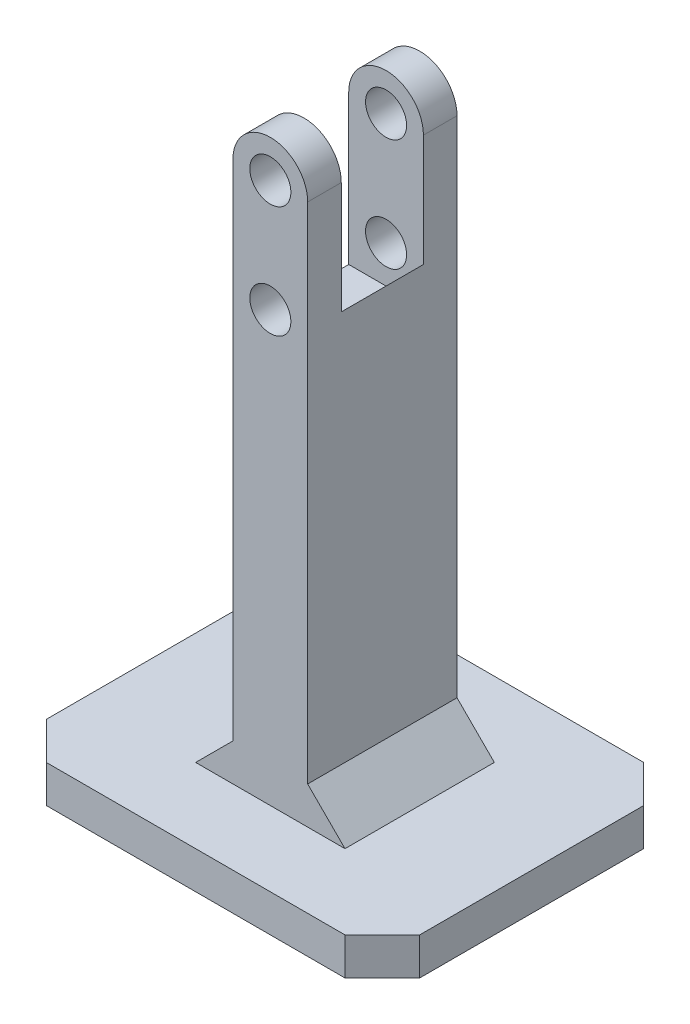
from build123d import *

# Parameters (mm, degrees)
BOSS_EXTRUDE1_DEPTH  = 10
M5_CLEARANCE_HOLE1_D = 5.5
CUT_EXTRUDE1_DEPTH   = 5.5
BOSS_EXTRUDE2_DEPTH  = 20
CHAMFER1_SIZE        = 5


with BuildPart() as part:
    # Sketch1 → Boss-Extrude1 (new, symmetric)
    with BuildSketch(Plane.XY):
        with BuildLine():
            Line((-5, -65), (-25, -65))
            Line((-25, -65), (-25, -70))
            Line((-25, -70), (25, -70))
            Line((25, -70), (25, -65))
            Line((25, -65), (5, -65))
            Line((5, -65), (5, 7.5))
            ThreePointArc((5, 7.5), (0, 12.5), (-5, 7.5))
            Line((-5, 7.5), (-5, -65))
        make_face()
    extrude(amount=BOSS_EXTRUDE1_DEPTH, both=True)

    # M5 Clearance Hole1 (through all)
    with Locations(Plane.XY.offset(10)):
        with Locations((0, 7.5), (0, -7.5)):
            Hole(M5_CLEARANCE_HOLE1_D / 2)

    # Sketch1_3 → Cut-Extrude1 (cut, symmetric)
    with BuildSketch(Plane.XY):
        with BuildLine():
            ThreePointArc((0, -12.5), (3.535533906, -11.035533906), (5, -7.5))
            Line((5, -7.5), (5, 7.5))
            ThreePointArc((5, 7.5), (0, 12.5), (-5, 7.5))
            Line((-5, 7.5), (-5, -12.5))
            Line((-5, -12.5), (0, -12.5))
        make_face()
    extrude(amount=CUT_EXTRUDE1_DEPTH, both=True, mode=Mode.SUBTRACT)

    # Sketch1_4 → Boss-Extrude2 (add, symmetric)
    with BuildSketch(Plane.XY):
        Polygon((25, -65), (5, -65), (-5, -65), (-25, -65), (-25, -70), (25, -70), align=None)
    extrude(amount=BOSS_EXTRUDE2_DEPTH, both=True)

    # Chamfer1
    chamfer1_edges = [part.edges().sort_by_distance(p)[0] for p in [
        (5, -65, 0),
        (-5, -65, 0),
        (25, -67.5, -20),
        (-25, -67.5, -20),
        (25, -67.5, 20),
        (-25, -67.5, 20),
    ]]
    chamfer(chamfer1_edges, length=CHAMFER1_SIZE)


solid = part.part
